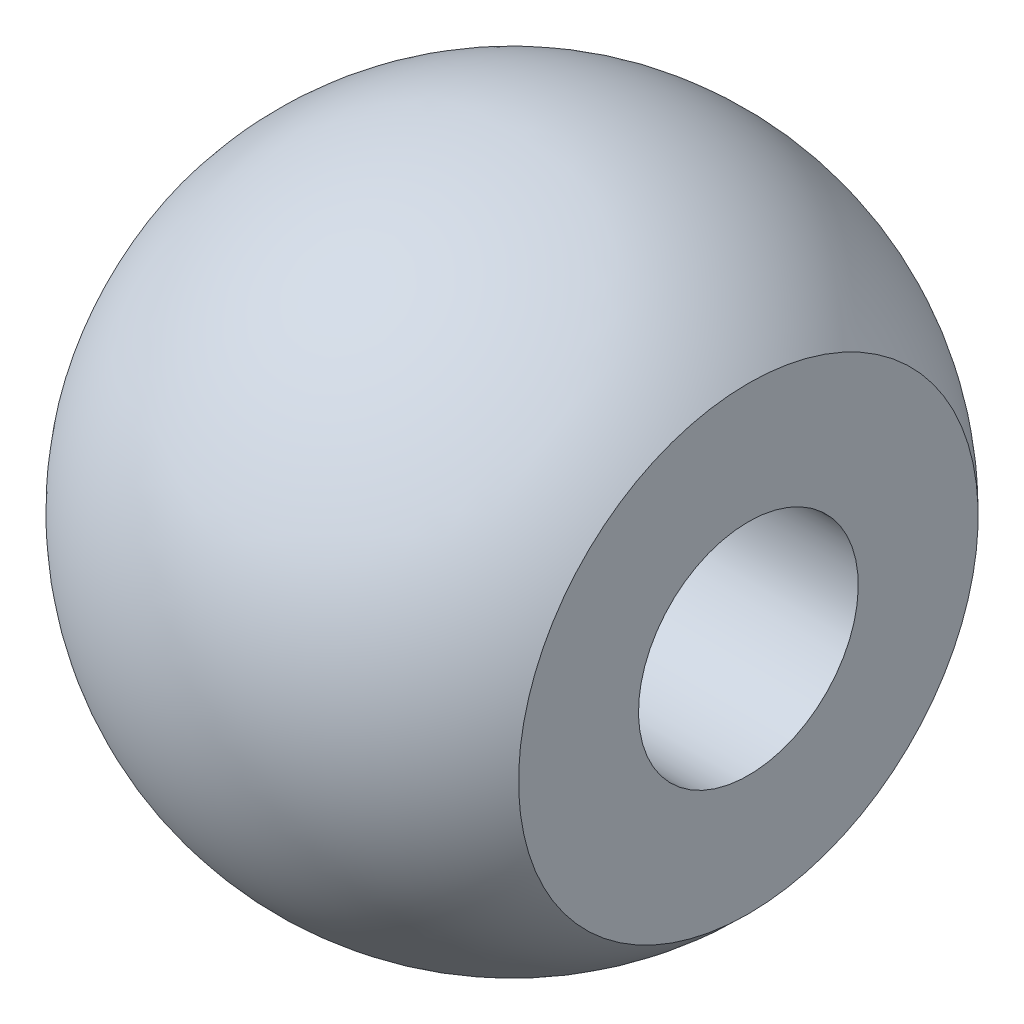
from build123d import *


with BuildPart() as part:
    # Sketch1 → Revolve1 (revolve)
    with BuildSketch(Plane.XY):
        with BuildLine():
            Line((-3.698063087, -2), (4.301936913, -2))
            Line((4.301936913, -2), (4.301936913, -4.182503891))
            ThreePointArc((4.301936913, -4.182503891), (-0.299926627, -5.992498979), (-4.698063087, -3.732050808))
            Line((-4.698063087, -3.732050808), (-3.698063087, -2))
        make_face()
    revolve(axis=Axis((0.62025974, 0, 0), (-1, 0, 0)))


solid = part.part
